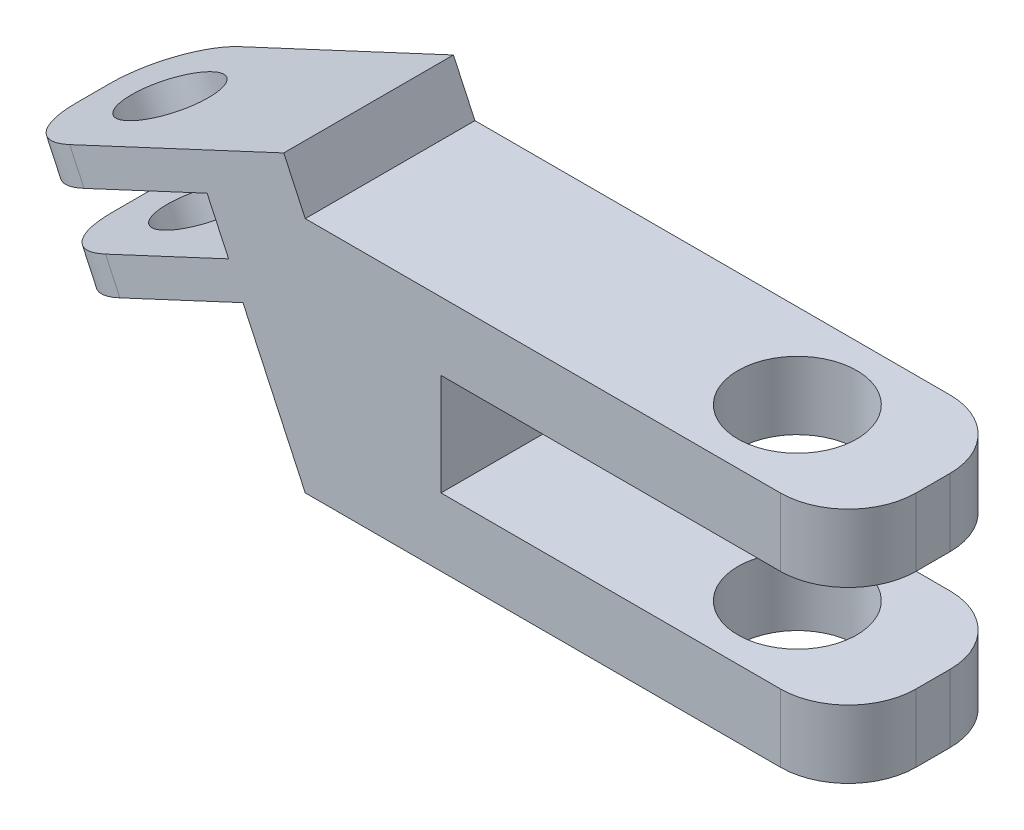
from build123d import *

# Parameters (mm, degrees)
BOSS_EXTRUDE1_DEPTH = 2.5
SKETCH2_R           = 1.25
CUT_EXTRUDE1_DEPTH  = 7.931238628
SKETCH3_R           = 1.75
CUT_EXTRUDE2_DEPTH  = 8
FILLET1_R           = 2


with BuildPart() as part:
    # Sketch1 → Boss-Extrude1 (new body, symmetric)
    with BuildSketch(Plane.XY):
        Polygon((16, -1.5), (16, -3.5), (0, -3.5), (-1.835919027, 0.43714106), (-7.27376575, -2.098568511), (-7.696384011, -1.192260724), (-2.258537289, 1.343448847), (-2.892464682, 2.702910527), (-8.330311404, 0.167200957), (-8.752929666, 1.073508744), (-0.633927393, 4.859461681), (0, 3.5), (16, 3.5), (16, 1.5), (4, 1.5), (4, -1.5), align=None)
    extrude(amount=BOSS_EXTRUDE1_DEPTH, both=True)

    # Sketch2 → Cut-Extrude1 (cut, through all)
    with BuildSketch(Plane(origin=(-0.495341252, 1.062262743, 0), x_dir=(0.906307787, 0.422618262, 0), z_dir=(0.422618262, -0.906307787, 0))):
        with Locations((-4.979163916, 0)):
            Circle(SKETCH2_R)
    extrude(amount=-CUT_EXTRUDE1_DEPTH, mode=Mode.SUBTRACT)

    # Sketch3 → Cut-Extrude2 (cut, through all)
    with BuildSketch(Plane(origin=(0, 3.5, 0), x_dir=(1, 0, 0), z_dir=(0, 1, 0))):
        with Locations((12, 0)):
            Circle(SKETCH3_R)
    extrude(amount=-CUT_EXTRUDE2_DEPTH, mode=Mode.SUBTRACT)

    # Fillet1
    fillet1_edges = [part.edges().sort_by_distance(p)[0] for p in [
        (-7.485074881, -1.645414617, -2.5),
        (-8.541620535, 0.62035485, -2.5),
        (16, 2.5, -2.5),
        (16, -2.5, -2.5),
        (16, 2.5, 2.5),
        (-8.541620535, 0.62035485, 2.5),
        (16, -2.5, 2.5),
        (-7.485074881, -1.645414617, 2.5),
    ]]
    fillet(fillet1_edges, radius=FILLET1_R)


solid = part.part
